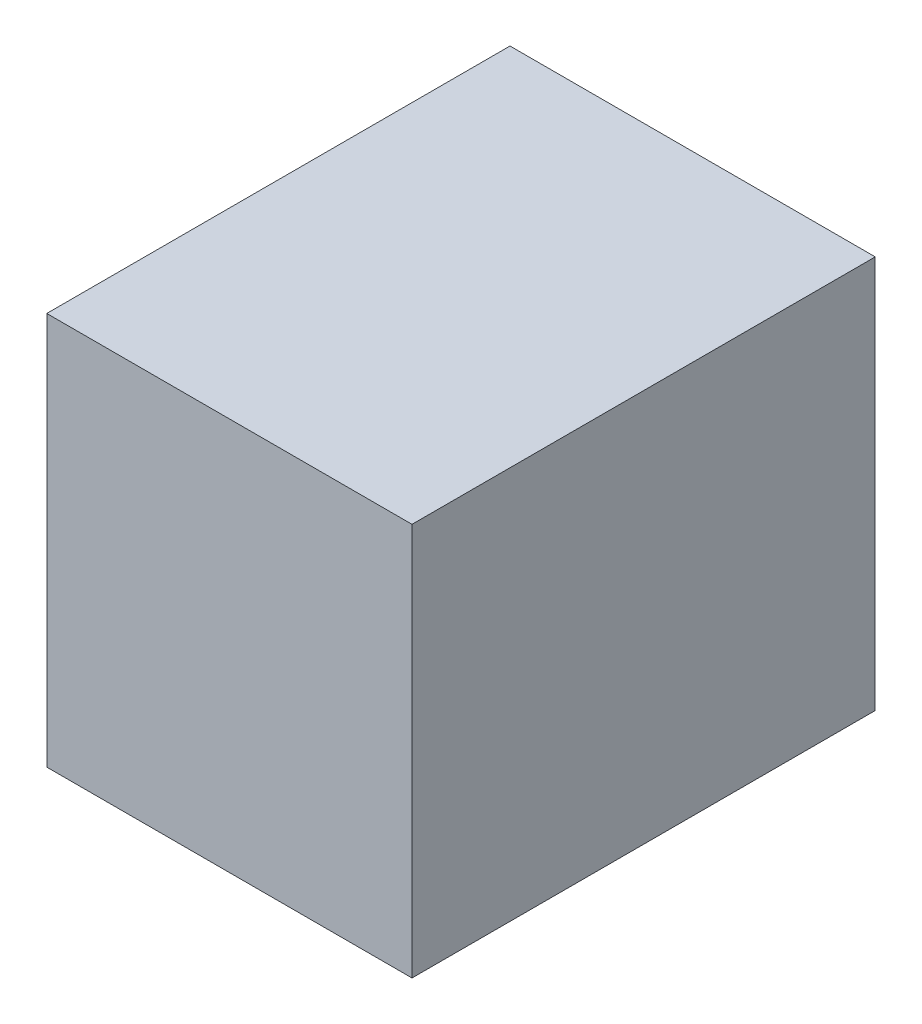
from build123d import *

# Parameters (mm, degrees)
SKETCH1_W           = 400
SKETCH1_H           = 421.052631578
BOSS_EXTRUDE1_DEPTH = 500
SHELL2_T            = 10


with BuildPart() as part:
    # Sketch1 → Boss-Extrude1 (new body)
    with BuildSketch(Plane.XY):
        with Locations((-100, 100)):
            Rectangle(SKETCH1_W, SKETCH1_H)
    extrude(amount=-BOSS_EXTRUDE1_DEPTH)

    # Shell2
    shell2_openings = [part.faces().sort_by_distance(p)[0] for p in [
        (-300, 100, -250),
    ]]
    offset(amount=SHELL2_T, openings=shell2_openings, kind=Kind.INTERSECTION)


solid = part.part
